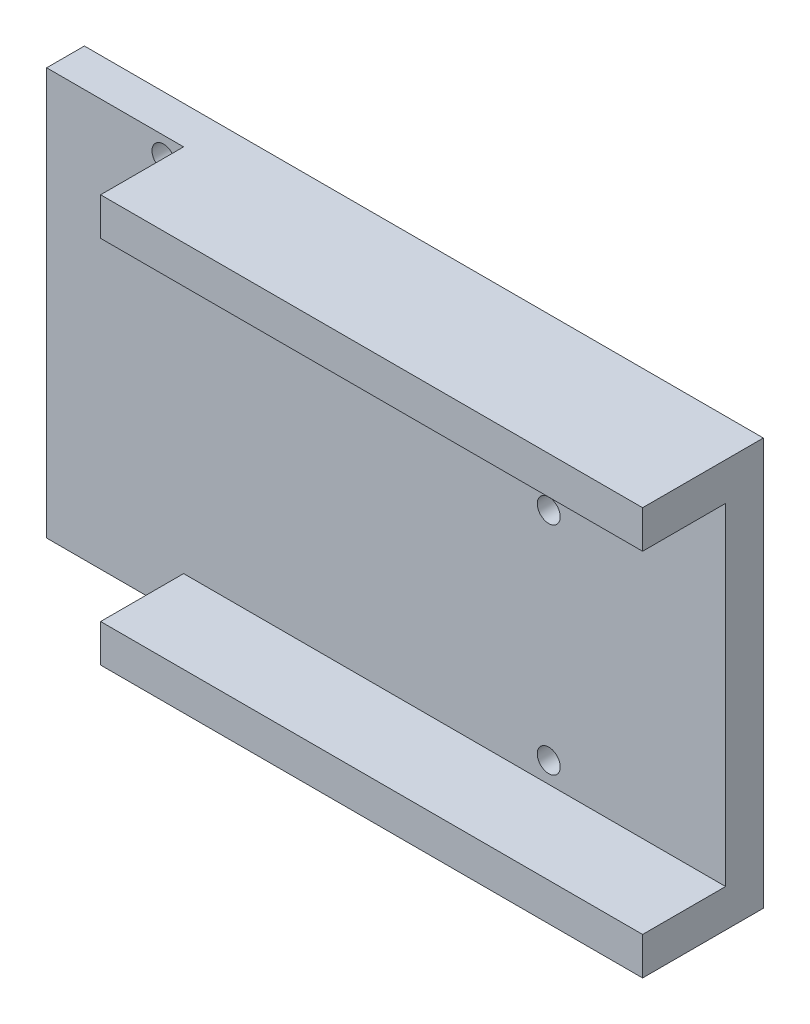
from build123d import *

# Parameters (mm, degrees)
SKETCH_1_W          = 89.974599949
SKETCH_1_H          = 53.974599949
EXTRUDE_1_DEPTH     = 16
SHELL_1_T           = -5
SKETCH_2_W          = 11
SKETCH_2_H          = 43.974599949
CUT_EXTRUDE_1_DEPTH = 90.974599949
SKETCH_3_W          = 18.148336296
SKETCH_3_H          = 11
CUT_EXTRUDE_2_DEPTH = 54.974599949
SKETCH_4_R          = 1.524003048
CUT_EXTRUDE_3_DEPTH = 17


with BuildPart() as part:
    # 草图1 → 凸台-拉伸1 (new body)
    with BuildSketch(Plane.XY):
        with Locations((-75.588712629, -507.770940429)):
            Rectangle(SKETCH_1_W, SKETCH_1_H)
    extrude(amount=-EXTRUDE_1_DEPTH)

    # 抽壳1
    shell_1_openings = [part.faces().sort_by_distance(p)[0] for p in [
        (-75.588712629, -507.770940429, 0),
    ]]
    offset(amount=SHELL_1_T, openings=shell_1_openings, kind=Kind.INTERSECTION)

    # 草图2 → 切除-拉伸1 (cut, through all)
    with BuildSketch(Plane.ZY.offset(120.576012603)):
        with Locations((-5.5, -507.770940429)):
            Rectangle(SKETCH_2_W, SKETCH_2_H)
    extrude(amount=-CUT_EXTRUDE_1_DEPTH, mode=Mode.SUBTRACT)

    # 草图3 → 切除-拉伸2 (cut, through all)
    with BuildSketch(Plane.XZ.offset(534.758240403)):
        with Locations((-111.501844455, -5.5)):
            Rectangle(SKETCH_3_W, SKETCH_3_H)
    extrude(amount=-CUT_EXTRUDE_2_DEPTH, mode=Mode.SUBTRACT)

    # 草图4 → 切除-拉伸3 (cut, through all)
    with BuildSketch(Plane.XY):
        with Locations((-105.092649637, -483.310945509)):
            Circle(SKETCH_4_R)
        with Locations((-54.038547528, -526.999032885)):
            Circle(SKETCH_4_R)
        with Locations((-54.038547528, -498.296975481)):
            Circle(SKETCH_4_R)
    extrude(amount=-CUT_EXTRUDE_3_DEPTH, mode=Mode.SUBTRACT)


solid = part.part
